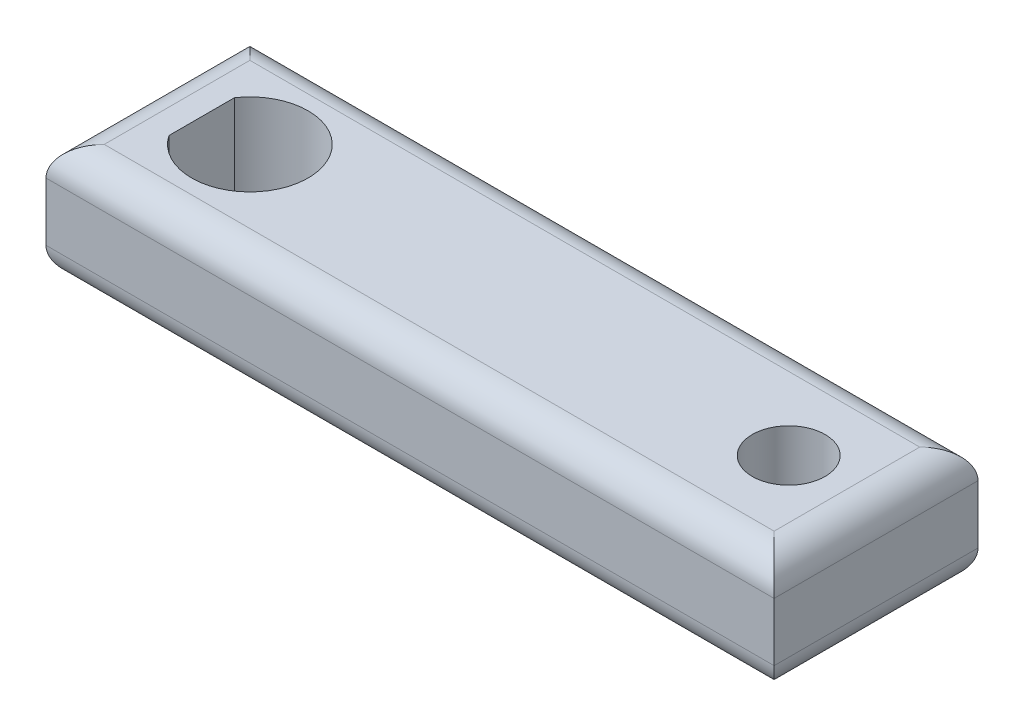
from build123d import *

# Parameters (mm, degrees)
SKETCH2_W           = 50
SKETCH2_H           = 14
BOSS_EXTRUDE1_DEPTH = 8
SKETCH3_R           = 2.5
CUT_EXTRUDE2_DEPTH  = 9
FILLET5_R           = 2


with BuildPart() as part:
    # Sketch2 → Boss-Extrude1 (new body)
    with BuildSketch(Plane(origin=(0, 0, 0), x_dir=(1, 0, 0), z_dir=(0, 1, 0))):
        Rectangle(SKETCH2_W, SKETCH2_H)
    extrude(amount=BOSS_EXTRUDE1_DEPTH)

    # Sketch3 → Cut-Extrude2 (cut, symmetric)
    with BuildSketch(Plane(origin=(0, 8, 0), x_dir=(1, 0, 0), z_dir=(0, 1, 0))):
        with Locations((19, 0)):
            Circle(SKETCH3_R)
        with BuildLine():
            Line((-21.307189139, 2.25), (-21.307189139, -2.25))
            ThreePointArc((-21.307189139, -2.25), (-14, 0), (-21.307189139, 2.25))
        make_face()
    extrude(amount=CUT_EXTRUDE2_DEPTH, both=True, mode=Mode.SUBTRACT)

    # Fillet5
    fillet5_edges = [part.edges().sort_by_distance(p)[0] for p in [
        (-25, 8, 0),
        (0, 8, 7),
        (25, 8, 0),
        (0, 0, 7),
        (-25, 0, 0),
        (0, 0, -7),
        (25, 0, 0),
        (0, 8, -7),
    ]]
    fillet(fillet5_edges, radius=FILLET5_R)


solid = part.part
